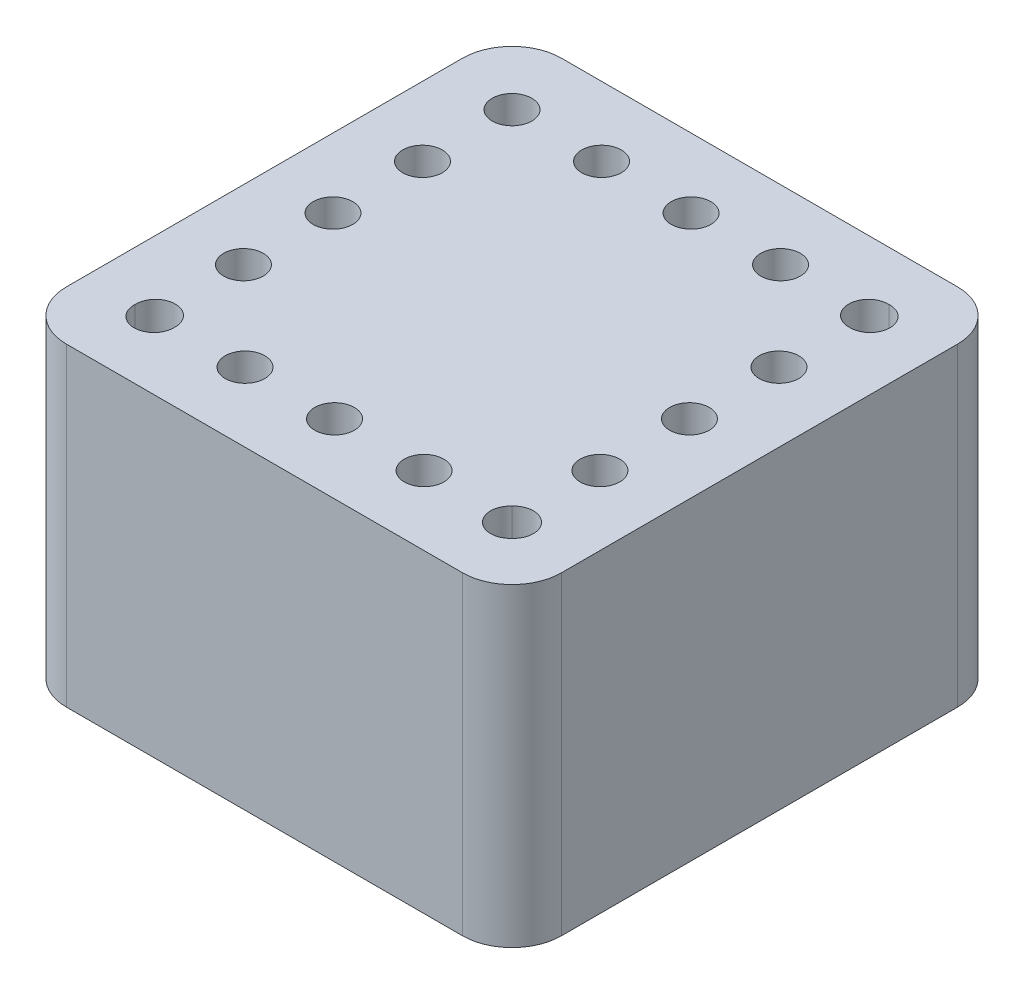
from build123d import *

# Parameters (mm, degrees)
SKETCH1_W               = 10
SKETCH1_H               = 10
BOSS_EXTRUDE1_DEPTH     = 6.35
FILLET1_R               = 1
SKETCH2_R               = 0.4
CUT_EXTRUDE1_DEPTH      = 1.6
LPATTERN1_COUNT         = 5
LPATTERN1_PITCH         = 1.808
LPATTERN2_COUNT         = 5
LPATTERN2_PITCH         = 1.808
MIRROR2_COPY_1_SKETCH_R = 0.4
MIRROR2_COPY_1_DEPTH    = 1.6
MIRROR2_COPY_2_SKETCH_R = 0.4
MIRROR2_COPY_2_DEPTH    = 1.6
MIRROR2_COPY_3_SKETCH_R = 0.4
MIRROR2_COPY_3_DEPTH    = 1.6
MIRROR2_COPY_4_SKETCH_R = 0.4
MIRROR2_COPY_4_DEPTH    = 1.6
MIRROR3_COPY_1_SKETCH_R = 0.4
MIRROR3_COPY_1_DEPTH    = 1.6
MIRROR3_COPY_2_SKETCH_R = 0.4
MIRROR3_COPY_2_DEPTH    = 1.6
MIRROR3_COPY_3_SKETCH_R = 0.4
MIRROR3_COPY_3_DEPTH    = 1.6
MIRROR3_COPY_4_SKETCH_R = 0.4
MIRROR3_COPY_4_DEPTH    = 1.6


with BuildPart() as part:
    # Sketch1 → Boss-Extrude1 (new body)
    with BuildSketch(Plane(origin=(0, 0, 0), x_dir=(1, 0, 0), z_dir=(0, 1, 0))):
        with Locations((5, 5)):
            Rectangle(SKETCH1_W, SKETCH1_H)
    extrude(amount=BOSS_EXTRUDE1_DEPTH)

    # Fillet1
    fillet1_edges = [part.edges().sort_by_distance(p)[0] for p in [
        (0, 3.175, -10),
        (10, 3.175, -10),
        (10, 3.175, 0),
        (0, 3.175, 0),
    ]]
    fillet(fillet1_edges, radius=FILLET1_R)

    # Sketch2 → Cut-Extrude1 (cut)
    with BuildSketch(Plane(origin=(0, 6.35, 0), x_dir=(1, 0, 0), z_dir=(0, 1, 0))):
        with Locations((1.4, 8.6)):
            Circle(SKETCH2_R)
    cut_extrude1 = extrude(amount=-CUT_EXTRUDE1_DEPTH, mode=Mode.SUBTRACT)

    # LPattern1: Cut-Extrude1 ×5
    with Locations(*[(i * LPATTERN1_PITCH, 0, 0) for i in range(1, LPATTERN1_COUNT)]):
        add(cut_extrude1, mode=Mode.SUBTRACT)

    # LPattern2: Cut-Extrude1 ×5
    with Locations(*[(0, 0, i * LPATTERN2_PITCH) for i in range(1, LPATTERN2_COUNT)]):
        add(cut_extrude1, mode=Mode.SUBTRACT)

    # Mirror2: Cut-Extrude1 across plane
    add(cut_extrude1.mirror(Plane.ZY.offset(-5)), mode=Mode.SUBTRACT)

    # Mirror2 copy 1 sketch → Mirror2 copy 1 (cut)
    with BuildSketch(Plane(origin=(10, 6.35, 1.808), x_dir=(-1, 0, 0), z_dir=(0, 1, 0))):
        with Locations((1.4, -8.6)):
            Circle(MIRROR2_COPY_1_SKETCH_R)
    extrude(amount=-MIRROR2_COPY_1_DEPTH, mode=Mode.SUBTRACT)

    # Mirror2 copy 2 sketch → Mirror2 copy 2 (cut)
    with BuildSketch(Plane(origin=(10, 6.35, 3.616), x_dir=(-1, 0, 0), z_dir=(0, 1, 0))):
        with Locations((1.4, -8.6)):
            Circle(MIRROR2_COPY_2_SKETCH_R)
    extrude(amount=-MIRROR2_COPY_2_DEPTH, mode=Mode.SUBTRACT)

    # Mirror2 copy 3 sketch → Mirror2 copy 3 (cut)
    with BuildSketch(Plane(origin=(10, 6.35, 5.424), x_dir=(-1, 0, 0), z_dir=(0, 1, 0))):
        with Locations((1.4, -8.6)):
            Circle(MIRROR2_COPY_3_SKETCH_R)
    extrude(amount=-MIRROR2_COPY_3_DEPTH, mode=Mode.SUBTRACT)

    # Mirror2 copy 4 sketch → Mirror2 copy 4 (cut)
    with BuildSketch(Plane(origin=(10, 6.35, 7.232), x_dir=(-1, 0, 0), z_dir=(0, 1, 0))):
        with Locations((1.4, -8.6)):
            Circle(MIRROR2_COPY_4_SKETCH_R)
    extrude(amount=-MIRROR2_COPY_4_DEPTH, mode=Mode.SUBTRACT)

    # Mirror3: Cut-Extrude1 across plane
    add(cut_extrude1.mirror(Plane(origin=(0, 0, -5), x_dir=(1, 0, 0), z_dir=(0, 0, -1))), mode=Mode.SUBTRACT)

    # Mirror3 copy 1 sketch → Mirror3 copy 1 (cut)
    with BuildSketch(Plane(origin=(1.808, 6.35, -10), x_dir=(1, 0, 0), z_dir=(0, 1, 0))):
        with Locations((1.4, -8.6)):
            Circle(MIRROR3_COPY_1_SKETCH_R)
    extrude(amount=-MIRROR3_COPY_1_DEPTH, mode=Mode.SUBTRACT)

    # Mirror3 copy 2 sketch → Mirror3 copy 2 (cut)
    with BuildSketch(Plane(origin=(3.616, 6.35, -10), x_dir=(1, 0, 0), z_dir=(0, 1, 0))):
        with Locations((1.4, -8.6)):
            Circle(MIRROR3_COPY_2_SKETCH_R)
    extrude(amount=-MIRROR3_COPY_2_DEPTH, mode=Mode.SUBTRACT)

    # Mirror3 copy 3 sketch → Mirror3 copy 3 (cut)
    with BuildSketch(Plane(origin=(5.424, 6.35, -10), x_dir=(1, 0, 0), z_dir=(0, 1, 0))):
        with Locations((1.4, -8.6)):
            Circle(MIRROR3_COPY_3_SKETCH_R)
    extrude(amount=-MIRROR3_COPY_3_DEPTH, mode=Mode.SUBTRACT)

    # Mirror3 copy 4 sketch → Mirror3 copy 4 (cut)
    with BuildSketch(Plane(origin=(7.232, 6.35, -10), x_dir=(1, 0, 0), z_dir=(0, 1, 0))):
        with Locations((1.4, -8.6)):
            Circle(MIRROR3_COPY_4_SKETCH_R)
    extrude(amount=-MIRROR3_COPY_4_DEPTH, mode=Mode.SUBTRACT)


solid = part.part
